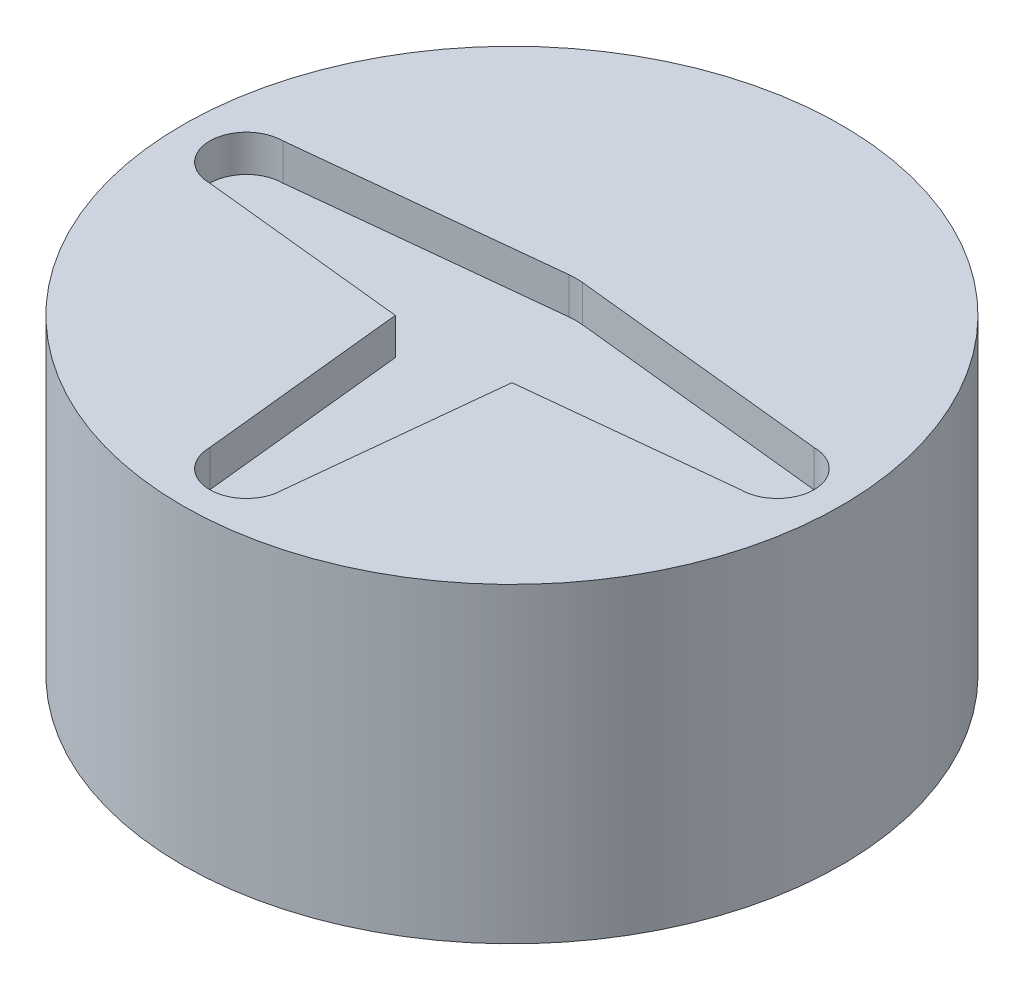
from build123d import *

# Parameters (mm, degrees)
SKETCH1_R           = 18
BOSS_EXTRUDE1_DEPTH = 17
SKETCH2_W           = 26
SKETCH2_H           = 14
CUT_EXTRUDE1_DEPTH  = 5.25
CUT_EXTRUDE2_DEPTH  = 2


with BuildPart() as part:
    # Sketch1 → Boss-Extrude1 (new body)
    with BuildSketch(Plane(origin=(0, 0, 0), x_dir=(1, 0, 0), z_dir=(0, 1, 0))):
        Circle(SKETCH1_R)
    extrude(amount=BOSS_EXTRUDE1_DEPTH)

    # Sketch2 → Cut-Extrude1 (cut)
    with BuildSketch(Plane.XZ):
        Rectangle(SKETCH2_W, SKETCH2_H)
    extrude(amount=-CUT_EXTRUDE1_DEPTH, mode=Mode.SUBTRACT)

    # Sketch3 → Cut-Extrude2 (cut)
    with BuildSketch(Plane(origin=(0, 17, 0), x_dir=(1, 0, 0), z_dir=(0, 1, 0))):
        with BuildLine():
            Line((14.5, 2), (0.364696883, 3.480947599))
            ThreePointArc((0.364696883, 3.480947599), (0, 3.5), (-0.364696883, 3.480947599))
            Line((-0.364696883, 3.480947599), (-14.5, 2))
            ThreePointArc((-14.5, 2), (-16.5, 0), (-14.5, -2))
            Line((-14.5, -2), (-3.185421861, -3.185421861))
            Line((-3.185421861, -3.185421861), (-2, -14.5))
            ThreePointArc((-2, -14.5), (0, -16.5), (2, -14.5))
            Line((2, -14.5), (3.185421861, -3.185421861))
            Line((3.185421861, -3.185421861), (14.5, -2))
            ThreePointArc((14.5, -2), (16.5, 0), (14.5, 2))
        make_face()
    extrude(amount=-CUT_EXTRUDE2_DEPTH, mode=Mode.SUBTRACT)


solid = part.part
